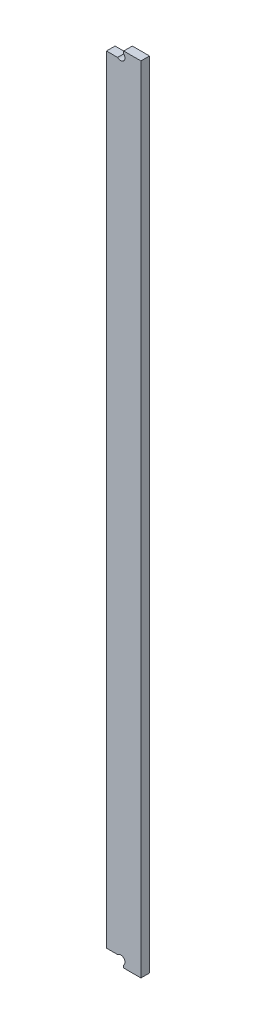
from build123d import *

# Parameters (mm, degrees)
BOSS_EXTRUDE1_DEPTH = 3.175
SKETCH3_R           = 1.5875
CUT_EXTRUDE1_DEPTH  = 3.175


with BuildPart() as part:
    # Sketch2 → Boss-Extrude1 (new body)
    with BuildSketch(Plane.XY):
        Polygon((39.6875, 291.062500032), (33.3375, 291.062500032), (33.3375, 287.887500032), (26.9875, 287.887500032), (26.9875, 1.5875), (33.3375, 1.5875), (33.3375, -1.5875), (39.6875, -1.5875), align=None)
    extrude(amount=BOSS_EXTRUDE1_DEPTH)

    # Sketch3 → Cut-Extrude1 (cut)
    with BuildSketch(Plane(origin=(0, 0, 0), x_dir=(-1, 0, 0), z_dir=(0, 0, -1))):
        with Locations((-32.214967985, 289.010032047)):
            Circle(SKETCH3_R)
        with Locations((-32.214967985, 0.464967985)):
            Circle(SKETCH3_R)
    extrude(amount=-CUT_EXTRUDE1_DEPTH, mode=Mode.SUBTRACT)


solid = part.part
